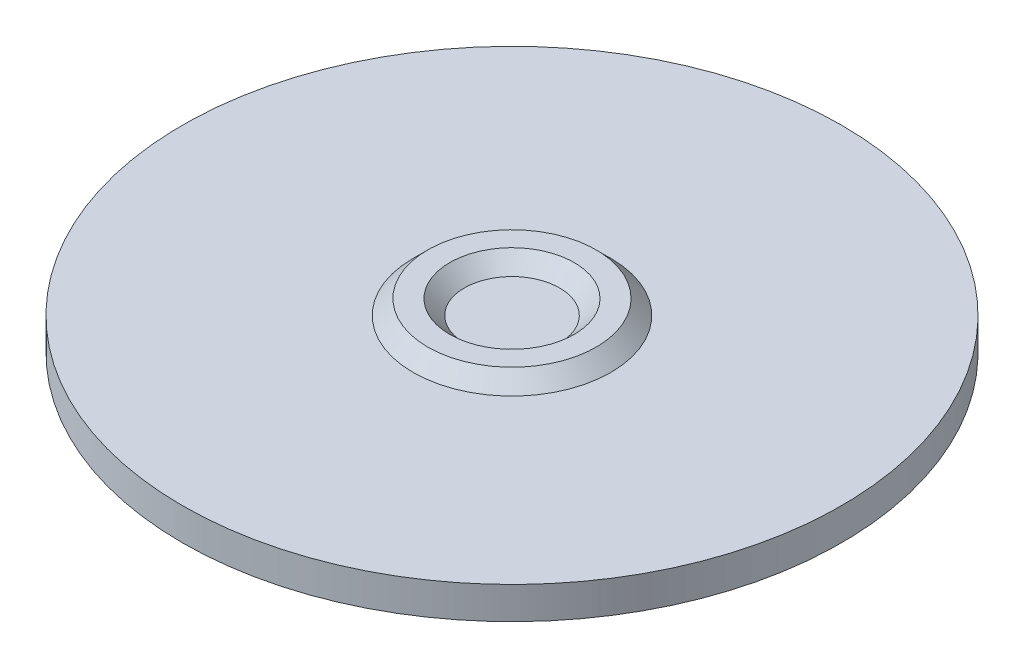
from build123d import *

# Parameters (mm, degrees)
SKETCH1_R           = 22.5
BOSS_EXTRUDE1_DEPTH = 2.2
SKETCH2_R           = 6.75
BOSS_EXTRUDE2_DEPTH = 1
BOSS_EXTRUDE2_TAPER = 45
SKETCH3_R           = 4.25
CUT_EXTRUDE1_DEPTH  = 1
CUT_EXTRUDE1_TAPER  = 45


with BuildPart() as part:
    # Sketch1 → Boss-Extrude1 (new body)
    with BuildSketch(Plane(origin=(0, 0, 0), x_dir=(1, 0, 0), z_dir=(0, 1, 0))):
        Circle(SKETCH1_R)
    extrude(amount=BOSS_EXTRUDE1_DEPTH)


with BuildPart() as body_2:
    # Sketch2 → Boss-Extrude2 (new body)
    with BuildSketch(Plane(origin=(0, 2.2, 0), x_dir=(1, 0, 0), z_dir=(0, 1, 0))):
        Circle(SKETCH2_R)
    extrude(amount=BOSS_EXTRUDE2_DEPTH, taper=BOSS_EXTRUDE2_TAPER)

    # Sketch3 → Cut-Extrude1 (cut)
    with BuildSketch(Plane(origin=(0, 3.2, 0), x_dir=(1, 0, 0), z_dir=(0, 1, 0))):
        Circle(SKETCH3_R)
    extrude(amount=-CUT_EXTRUDE1_DEPTH, taper=CUT_EXTRUDE1_TAPER, mode=Mode.SUBTRACT)


solid = Compound([part.part, body_2.part])
